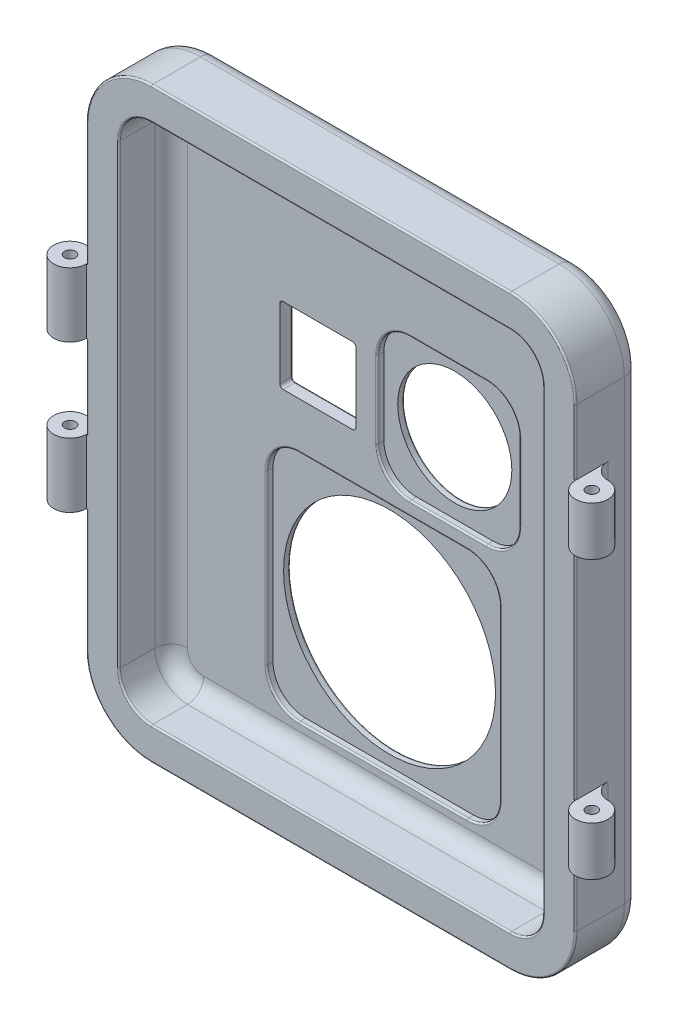
from build123d import *

# Parameters (mm, degrees)
BOSS_EXTRUDE1_DEPTH      = 20
SHELL1_T                 = -10
SHELL1_THICKNESS_2_DEPTH = 6
SKETCH3_R                = 32.5
CUT_EXTRUDE5_DEPTH       = 119.84864324
CUT_EXTRUDE6_DEPTH       = 119.84864324
SKETCH5_R                = 17.5
CUT_EXTRUDE7_DEPTH       = 119.84864324
SKETCH6_R                = 1.7
BOSS_EXTRUDE2_DEPTH      = 50
SKETCH6_2_R              = 1.7
CUT_EXTRUDE8_DEPTH       = 35
SKETCH9_R                = 1.7
BOSS_EXTRUDE3_DEPTH      = 32.5
SKETCH9_2_R              = 1.7
CUT_EXTRUDE10_DEPTH      = 12.75
CUT_EXTRUDE9_DEPTH       = 2
FILLET1_R                = 5
FILLET2_R                = 0.5


with BuildPart() as part:
    # Sketch1 → Boss-Extrude1 (new body)
    with BuildSketch(Plane.XY):
        with BuildLine():
            Line((55, -90), (-55, -90))
            ThreePointArc((-55, -90), (-69.142135624, -84.142135624), (-75, -70))
            Line((-75, -70), (-75, 70))
            ThreePointArc((-75, 70), (-69.142135624, 84.142135624), (-55, 90))
            Line((-55, 90), (55, 90))
            ThreePointArc((55, 90), (69.142135624, 84.142135624), (75, 70))
            Line((75, 70), (75, -70))
            ThreePointArc((75, -70), (69.142135624, -84.142135624), (55, -90))
        make_face()
    extrude(amount=BOSS_EXTRUDE1_DEPTH)

    # Shell1
    shell1_openings = [part.faces().sort_by_distance(p)[0] for p in [
        (0, 0, 20),
    ]]
    offset(amount=SHELL1_T, openings=shell1_openings, kind=Kind.INTERSECTION)

    # Shell1 thickness 2 face (on inner face of the shell) → Shell1 thickness 2 (cut)
    with BuildSketch(Plane(origin=(0, 0, 10), x_dir=(-1, 0, 0), z_dir=(0, 0, -1))):
        with BuildLine():
            ThreePointArc((-55, -80), (-62.071067812, -77.071067812), (-65, -70))
            Line((-65, -70), (-65, 70))
            ThreePointArc((-65, 70), (-62.071067812, 77.071067812), (-55, 80))
            Line((-55, 80), (55, 80))
            ThreePointArc((55, 80), (62.071067812, 77.071067812), (65, 70))
            Line((65, 70), (65, -70))
            ThreePointArc((65, -70), (62.071067812, -77.071067812), (55, -80))
            Line((55, -80), (-55, -80))
        make_face()
    extrude(amount=SHELL1_THICKNESS_2_DEPTH, mode=Mode.SUBTRACT)

    # Sketch3 → Cut-Extrude5 (cut, through all)
    with BuildSketch(Plane.XY):
        with Locations((0, -36.75)):
            Circle(SKETCH3_R)
    extrude(amount=CUT_EXTRUDE5_DEPTH, mode=Mode.SUBTRACT)

    # Sketch4 → Cut-Extrude6 (cut, through all)
    with BuildSketch(Plane.XY):
        with BuildLine():
            Line((-30.675, 13.325), (-9.325, 13.325))
            ThreePointArc((-9.325, 13.325), (-8.617893219, 13.617893219), (-8.325, 14.325))
            Line((-8.325, 14.325), (-8.325, 35.675))
            ThreePointArc((-8.325, 35.675), (-8.617893219, 36.382106781), (-9.325, 36.675))
            Line((-9.325, 36.675), (-30.675, 36.675))
            ThreePointArc((-30.675, 36.675), (-31.382106781, 36.382106781), (-31.675, 35.675))
            Line((-31.675, 35.675), (-31.675, 14.325))
            ThreePointArc((-31.675, 14.325), (-31.382106781, 13.617893219), (-30.675, 13.325))
        make_face()
    extrude(amount=CUT_EXTRUDE6_DEPTH, mode=Mode.SUBTRACT)

    # Sketch5 → Cut-Extrude7 (cut, through all)
    with BuildSketch(Plane.XY):
        with Locations((20, 25)):
            Circle(SKETCH5_R)
    extrude(amount=CUT_EXTRUDE7_DEPTH, mode=Mode.SUBTRACT)

    # Sketch6 → Boss-Extrude2 (add, symmetric)
    with BuildSketch(Plane(origin=(0, 0, 0), x_dir=(1, 0, 0), z_dir=(0, 1, 0))):
        with BuildLine():
            Line((75, -20), (75, -10))
            ThreePointArc((75, -10), (76.464466094, -13.535533906), (80, -15))
            ThreePointArc((80, -15), (83.535533906, -23.535533906), (75, -20))
        make_face()
        with Locations((80, -20)):
            Circle(SKETCH6_R, mode=Mode.SUBTRACT)
    extrude(amount=BOSS_EXTRUDE2_DEPTH, both=True)

    # Sketch6_2 → Cut-Extrude8 (cut, symmetric)
    with BuildSketch(Plane(origin=(0, 0, 0), x_dir=(1, 0, 0), z_dir=(0, 1, 0))):
        with BuildLine():
            Line((75, -20), (75, -10))
            ThreePointArc((75, -10), (76.464466094, -13.535533906), (80, -15))
            ThreePointArc((80, -15), (83.535533906, -23.535533906), (75, -20))
        make_face()
        with Locations((80, -20)):
            Circle(SKETCH6_2_R, mode=Mode.SUBTRACT)
    extrude(amount=CUT_EXTRUDE8_DEPTH, both=True, mode=Mode.SUBTRACT)

    # Sketch9 → Boss-Extrude3 (add, symmetric)
    with BuildSketch(Plane(origin=(0, 0, 0), x_dir=(1, 0, 0), z_dir=(0, 1, 0))):
        with BuildLine():
            Line((-75, -10), (-75, -20))
            ThreePointArc((-75, -20), (-83.535533906, -23.535533906), (-80, -15))
            ThreePointArc((-80, -15), (-76.464466094, -13.535533906), (-75, -10))
        make_face()
        with Locations((-80, -20)):
            Circle(SKETCH9_R, mode=Mode.SUBTRACT)
    extrude(amount=BOSS_EXTRUDE3_DEPTH, both=True)

    # Sketch9_2 → Cut-Extrude10 (cut, symmetric)
    with BuildSketch(Plane(origin=(0, 0, 0), x_dir=(1, 0, 0), z_dir=(0, 1, 0))):
        with BuildLine():
            Line((-75, -10), (-75, -20))
            ThreePointArc((-75, -20), (-83.535533906, -23.535533906), (-80, -15))
            ThreePointArc((-80, -15), (-76.464466094, -13.535533906), (-75, -10))
        make_face()
        with Locations((-80, -20)):
            Circle(SKETCH9_2_R, mode=Mode.SUBTRACT)
    extrude(amount=CUT_EXTRUDE10_DEPTH, both=True, mode=Mode.SUBTRACT)

    # Sketch7 → Cut-Extrude9 (cut)
    with BuildSketch(Plane.XY.offset(4)):
        with BuildLine():
            Line((-25.75, -1), (25.75, -1))
            ThreePointArc((25.75, -1), (32.821067812, -3.928932188), (35.75, -11))
            Line((35.75, -11), (35.75, -62.5))
            ThreePointArc((35.75, -62.5), (32.821067812, -69.571067812), (25.75, -72.5))
            Line((25.75, -72.5), (-25.75, -72.5))
            ThreePointArc((-25.75, -72.5), (-32.821067812, -69.571067812), (-35.75, -62.5))
            Line((-35.75, -62.5), (-35.75, -11))
            ThreePointArc((-35.75, -11), (-32.821067812, -3.928932188), (-25.75, -1))
        make_face()
        with BuildLine():
            Line((8.25, 46.75), (31.75, 46.75))
            ThreePointArc((31.75, 46.75), (38.821067812, 43.821067812), (41.75, 36.75))
            Line((41.75, 36.75), (41.75, 13.25))
            ThreePointArc((41.75, 13.25), (38.821067812, 6.178932188), (31.75, 3.25))
            Line((31.75, 3.25), (8.25, 3.25))
            ThreePointArc((8.25, 3.25), (1.178932188, 6.178932188), (-1.75, 13.25))
            Line((-1.75, 13.25), (-1.75, 36.75))
            ThreePointArc((-1.75, 36.75), (1.178932188, 43.821067812), (8.25, 46.75))
        make_face()
    extrude(amount=-CUT_EXTRUDE9_DEPTH, mode=Mode.SUBTRACT)

    # Fillet1
    fillet1_edges = [part.edges().sort_by_distance(p)[0] for p in [
        (75, 0, 0),
        (69.142135624, -84.142135624, 0),
        (0, -90, 0),
        (-69.142135624, -84.142135624, 0),
        (-75, 0, 0),
        (-69.142135624, 84.142135624, 0),
        (0, 90, 0),
        (69.142135624, 84.142135624, 0),
        (0, 80, 4),
        (62.071067812, 77.071067812, 4),
        (65, 0, 4),
        (62.071067812, -77.071067812, 4),
        (0, -80, 4),
        (-62.071067812, -77.071067812, 4),
        (-65, 0, 4),
        (-62.071067812, 77.071067812, 4),
    ]]
    fillet(fillet1_edges, radius=FILLET1_R)

    # Fillet2
    fillet2_edges = [part.edges().sort_by_distance(p)[0] for p in [
        (-8.617893219, 13.617893219, 0),
        (-20, 13.325, 0),
        (-31.382106781, 13.617893219, 0),
        (-31.675, 25, 0),
        (-31.382106781, 36.382106781, 0),
        (-20, 36.675, 0),
        (-8.617893219, 36.382106781, 0),
        (75, 60, 20),
        (69.142135624, 84.142135624, 20),
        (0, 90, 20),
        (-69.142135624, 84.142135624, 20),
        (75, -60, 20),
        (69.142135624, -84.142135624, 20),
        (0, -90, 20),
        (-69.142135624, -84.142135624, 20),
        (-62.071067812, 77.071067812, 20),
        (0, 80, 20),
        (62.071067812, 77.071067812, 20),
        (65, 0, 20),
        (62.071067812, -77.071067812, 20),
        (0, -80, 20),
        (-62.071067812, -77.071067812, 20),
        (-8.325, 25, 0),
        (2.5, 25, 0),
        (75, 0, 20),
        (-75, 51.25, 20),
        (-75, -51.25, 20),
        (-75, 0, 20),
        (-65, 0, 20),
        (-32.5, -36.75, 0),
        (1.178932188, 43.821067812, 4),
        (20, 46.75, 4),
        (38.821067812, 43.821067812, 4),
        (41.75, 25, 4),
        (38.821067812, 6.178932188, 4),
        (20, 3.25, 4),
        (1.178932188, 6.178932188, 4),
        (32.821067812, -3.928932188, 4),
        (35.75, -36.75, 4),
        (32.821067812, -69.571067812, 4),
        (0, -72.5, 4),
        (-32.821067812, -69.571067812, 4),
        (-35.75, -36.75, 4),
        (-32.821067812, -3.928932188, 4),
        (-1.75, 25, 4),
        (0, -1, 4),
    ]]
    fillet(fillet2_edges, radius=FILLET2_R)


solid = part.part
